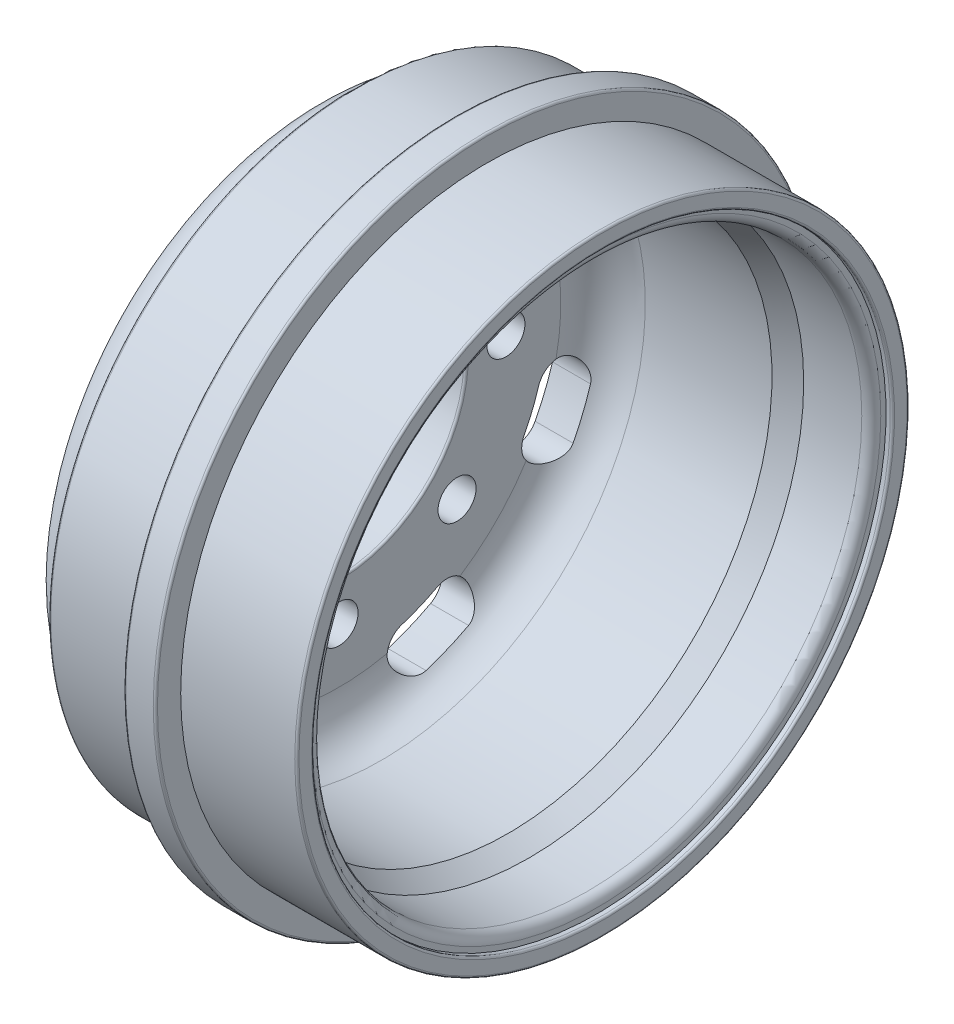
from build123d import *

# Parameters (mm, degrees)
ESQUISSE2_R                  = 0.9
TROU_MOYEU_DEPTH             = 2.75
REP_TROUS_MOYEU_COUNT        = 8
RAINURE_AERATION_DEPTH       = 14.75
R_P_TITION_CIRCULAIRE2_COUNT = 8
CONGES_R                     = 0.1


with BuildPart() as part:
    # Esquisse1 → rev_jante (revolve)
    with BuildSketch(Plane.XY, mode=Mode.PRIVATE) as rev_jante_sk:
        with BuildLine():
            Line((0, 6.025), (1.75, 6.025))
            Line((1.75, 6.025), (1.75, 10.5))
            ThreePointArc((1.75, 10.5), (2.335786438, 11.914213562), (3.75, 12.5))
            Line((3.75, 12.5), (9.75, 12.5))
            Line((9.75, 12.5), (10.75, 13))
            Line((10.75, 13), (13.5, 13))
            ThreePointArc((13.5, 13), (13.818198052, 13.131801948), (13.95, 13.45))
            Line((13.95, 13.45), (13.95, 13.7))
            Line((13.95, 13.7), (14.25, 13.7))
            Line((14.25, 13.7), (14.25, 14.5))
            Line((14.25, 14.5), (8.75, 14.5))
            Line((8.75, 14.5), (8.75, 15.7))
            Line((8.75, 15.7), (7.25, 15.7))
            Line((7.25, 15.7), (7.25, 14.5))
            Line((7.25, 14.5), (2.5, 14.5))
            Line((2.5, 14.5), (2.5, 13.5))
            Line((2.5, 13.5), (2, 13.5))
            ThreePointArc((2, 13.5), (0.939339828, 13.060660172), (0.5, 12))
            Line((0.5, 12), (0.5, 9.75))
            Line((0.5, 9.75), (0, 9.75))
            Line((0, 9.75), (0, 6.025))
        make_face()
    revolve(rev_jante_sk.sketch.rotate(Axis((0, 0, 0), (1, 0, 0)), 90), axis=Axis((0, 0, 0), (1, 0, 0)))  # turned: the seam where the file's is

    # Esquisse2 → trou_moyeu (cut, through all)
    with BuildSketch(Plane(origin=(1.75, 0, 0), x_dir=(0, 0, -1), z_dir=(1, 0, 0))):
        with Locations((7.9, 0)):
            Circle(ESQUISSE2_R)
    trou_moyeu = extrude(amount=-TROU_MOYEU_DEPTH, mode=Mode.SUBTRACT)

    # rep_trous_moyeu: trou_moyeu ×8 about axis
    rep_trous_moyeu_axis = Axis((0, 0, 0), (1, 0, 0))
    for i in range(1, REP_TROUS_MOYEU_COUNT):
        add(trou_moyeu.rotate(rep_trous_moyeu_axis, i * 360 / REP_TROUS_MOYEU_COUNT), mode=Mode.SUBTRACT)

    # Esquisse4 → rainure_aeration (cut, through all)
    with BuildSketch(Plane.ZY.offset(-0.5)):
        with BuildLine():
            ThreePointArc((5.581772892, 10.481385232), (4.595743194, 10.949647003), (3.570881369, 11.32538879))
            ThreePointArc((3.570881369, 11.32538879), (2.316458619, 10.672377639), (2.96946977, 9.417954889))
            ThreePointArc((2.96946977, 9.417954889), (3.821723288, 9.105495929), (4.641684826, 8.716099298))
            ThreePointArc((4.641684826, 8.716099298), (5.994371826, 9.128698232), (5.581772892, 10.481385232))
        make_face()
    rainure_aeration = extrude(amount=-RAINURE_AERATION_DEPTH, mode=Mode.SUBTRACT)

    # Répétition circulaire2: rainure_aeration ×8 about axis
    r_p_tition_circulaire2_axis = Axis((0, 0, 0), (1, 0, 0))
    for i in range(1, R_P_TITION_CIRCULAIRE2_COUNT):
        add(rainure_aeration.rotate(r_p_tition_circulaire2_axis, i * 360 / R_P_TITION_CIRCULAIRE2_COUNT), mode=Mode.SUBTRACT)

    # conges
    conges_edges = [part.edges().sort_by_distance(p)[0] for p in [
        (1.75, 0, -6.025),
        (14.25, 0, -13.7),
        (14.25, 0, -14.5),
        (8.75, 0, -15.7),
        (7.25, 0, -15.7),
        (2.5, 0, -14.5),
        (0.5, 0, -9.75),
        (0, 0, -9.75),
    ]]
    fillet(conges_edges, radius=CONGES_R)


solid = part.part
